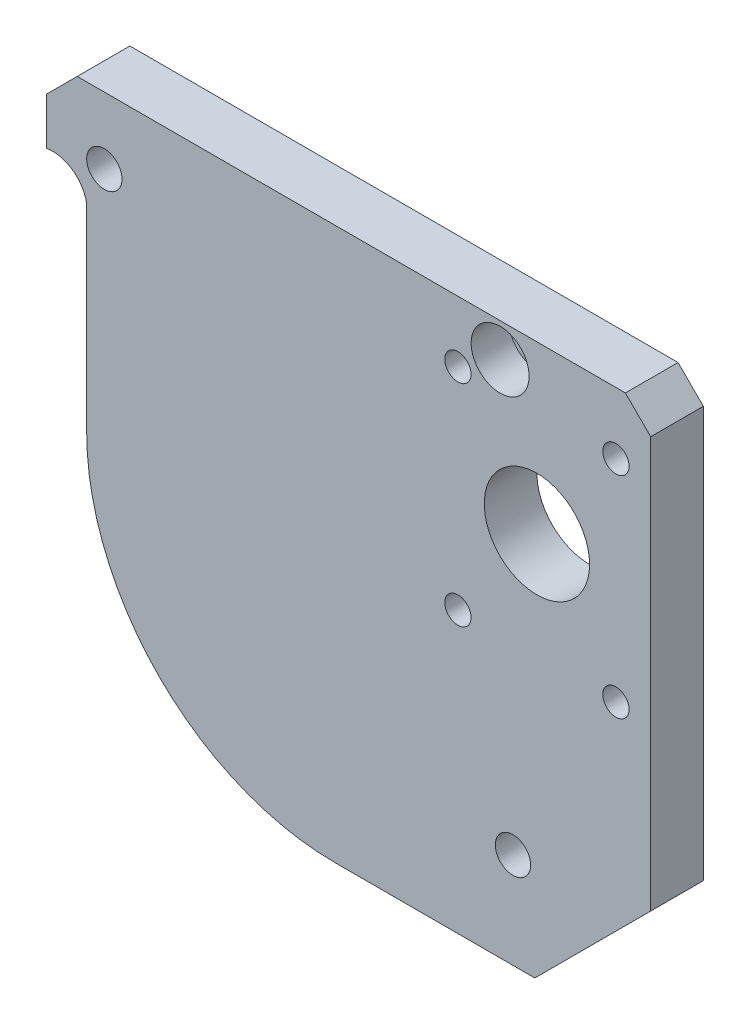
from build123d import *

# Parameters (mm, degrees)
SKETCH1_W                        = 72.8218
SKETCH1_H                        = 66.548
BOSS_EXTRUDE1_DEPTH              = 6.35
SKETCH2_R                        = 6.35
CUT_EXTRUDE1_DEPTH               = 7.35
SKETCH3_R                        = 2.12725
CUT_EXTRUDE2_DEPTH               = 7.35
SKETCH4_R                        = 2.12725
CUT_EXTRUDE3_DEPTH               = 7.35
SKETCH5_R                        = 2.12725
CUT_EXTRUDE4_DEPTH               = 7.35
SKETCH6_R                        = 3.4925
CUT_EXTRUDE5_DEPTH               = 4.572
F_1_8_0_125_DIAMETER_HOLE1_D     = 3.175
F_1_8_0_125_DIAMETER_HOLE1_DEPTH = 25.4
F_1_8_0_125_DIAMETER_HOLE1_TIP   = 0.953866233
CUT_EXTRUDE6_DEPTH               = 7.35
CUT_EXTRUDE7_DEPTH               = 7.35
CUT_EXTRUDE8_DEPTH               = 7.35
CUT_EXTRUDE9_DEPTH               = 7.35
CUT_EXTRUDE10_DEPTH              = 7.35


with BuildPart() as part:
    # Sketch1 → Boss-Extrude1 (new body)
    with BuildSketch(Plane.XY):
        with Locations((36.4109, 33.274)):
            Rectangle(SKETCH1_W, SKETCH1_H)
    extrude(amount=BOSS_EXTRUDE1_DEPTH)

    # Sketch2 → Cut-Extrude1 (cut, through all)
    with BuildSketch(Plane.XY.offset(6.35)):
        with Locations((59.1058, 46.482)):
            Circle(SKETCH2_R)
    extrude(amount=-CUT_EXTRUDE1_DEPTH, mode=Mode.SUBTRACT)

    # Sketch3 → Cut-Extrude2 (cut, through all)
    with BuildSketch(Plane.XY.offset(6.35)):
        with Locations((56.21655, 11.52525)):
            Circle(SKETCH3_R)
    extrude(amount=-CUT_EXTRUDE2_DEPTH, mode=Mode.SUBTRACT)

    # Sketch4 → Cut-Extrude3 (cut, through all)
    with BuildSketch(Plane.XY.offset(6.35)):
        with Locations((6.95325, 58.51525)):
            Circle(SKETCH4_R)
    extrude(amount=-CUT_EXTRUDE3_DEPTH, mode=Mode.SUBTRACT)

    # Sketch5 → Cut-Extrude4 (cut, through all)
    with BuildSketch(Plane.XY.offset(6.35)):
        with Locations((54.66715, 62.46495)):
            Circle(SKETCH5_R)
    extrude(amount=-CUT_EXTRUDE4_DEPTH, mode=Mode.SUBTRACT)

    # Sketch6 → Cut-Extrude5 (cut)
    with BuildSketch(Plane.XY.offset(6.35)):
        with Locations((54.66715, 62.46495)):
            Circle(SKETCH6_R)
    extrude(amount=-CUT_EXTRUDE5_DEPTH, mode=Mode.SUBTRACT)

    # 1/8 (0.125) Diameter Hole1
    with Locations(Plane.XY.offset(6.35)):
        with Locations((49.5808, 59.182), (68.6308, 59.109110049), (68.630660552, 33.70911005), (49.5808, 33.782)):
            Hole(F_1_8_0_125_DIAMETER_HOLE1_D / 2, depth=F_1_8_0_125_DIAMETER_HOLE1_DEPTH)
            with Locations((0, 0, -(F_1_8_0_125_DIAMETER_HOLE1_DEPTH + F_1_8_0_125_DIAMETER_HOLE1_TIP / 2))):  # 118° drill point
                Cone(0, F_1_8_0_125_DIAMETER_HOLE1_D / 2, F_1_8_0_125_DIAMETER_HOLE1_TIP, mode=Mode.SUBTRACT)

    # Sketch9 → Cut-Extrude6 (cut, through all)
    with BuildSketch(Plane.XY.offset(6.35)):
        Polygon((72.8218, 13.97), (58.8518, 0), (72.8218, 0), align=None)
    extrude(amount=-CUT_EXTRUDE6_DEPTH, mode=Mode.SUBTRACT)

    # Sketch10 → Cut-Extrude7 (cut, through all)
    with BuildSketch(Plane.XY.offset(6.35)):
        Polygon((3.683, 66.548), (0, 62.865), (0, 66.548), align=None)
    extrude(amount=-CUT_EXTRUDE7_DEPTH, mode=Mode.SUBTRACT)

    # Sketch11 → Cut-Extrude8 (cut, through all)
    with BuildSketch(Plane.XY.offset(6.35)):
        with BuildLine():
            Line((4.826, 53.831043168), (4.826, 0))
            Line((4.826, 0), (0, 0))
            Line((0, 0), (0, 57.192541634))
            ThreePointArc((0, 57.192541634), (3.109189127, 56.511289727), (4.826, 53.831043168))
        make_face()
    extrude(amount=-CUT_EXTRUDE8_DEPTH, mode=Mode.SUBTRACT)

    # Sketch12 → Cut-Extrude9 (cut, through all)
    with BuildSketch(Plane.XY.offset(6.35)):
        with BuildLine():
            Line((4.826, 29.972), (4.826, 0))
            Line((4.826, 0), (34.798, 0))
            ThreePointArc((34.798, 0), (13.604595554, 8.778595554), (4.826, 29.972))
        make_face()
    extrude(amount=-CUT_EXTRUDE9_DEPTH, mode=Mode.SUBTRACT)

    # Sketch13 → Cut-Extrude10 (cut, through all)
    with BuildSketch(Plane.XY.offset(6.35)):
        Polygon((69.7738, 66.548), (72.8218, 63.5), (72.8218, 66.548), align=None)
    extrude(amount=-CUT_EXTRUDE10_DEPTH, mode=Mode.SUBTRACT)


solid = part.part
